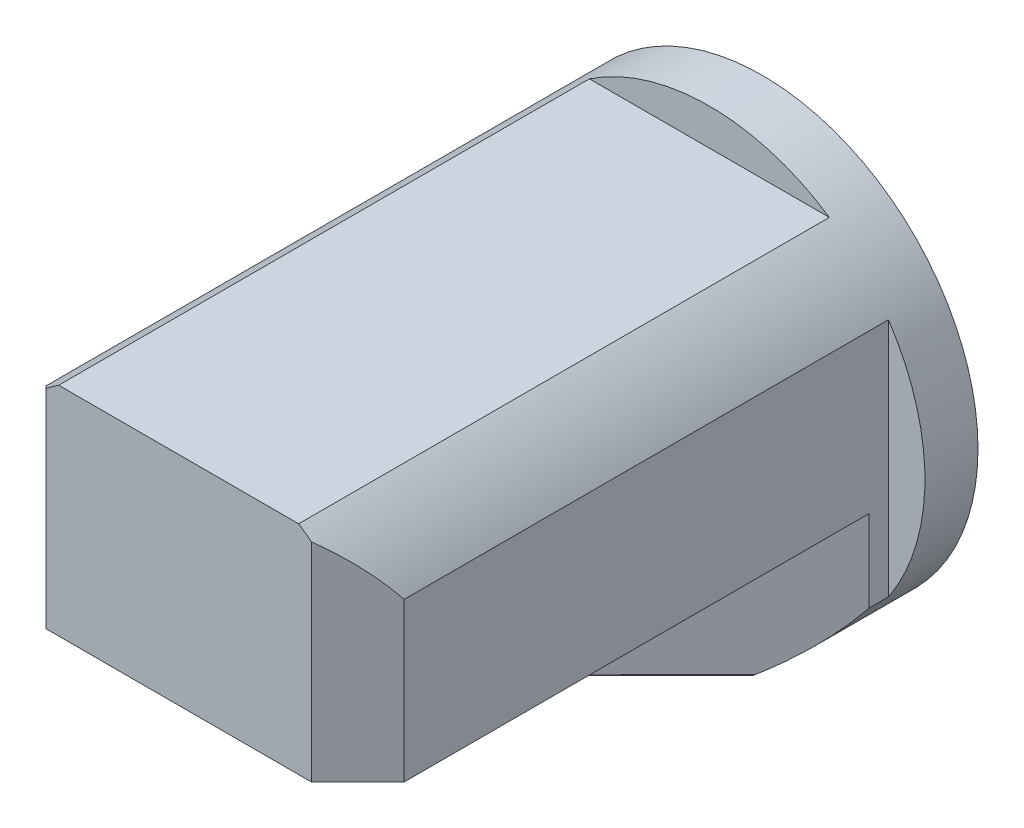
from build123d import *

# Parameters (mm, degrees)
SKETCH3_R             = 130
BOSS_EXTRUDE1_DEPTH   = 352
CUT_EXTRUDE2_START    = -320
CUT_EXTRUDE2_DEPTH    = 320
CUT_EXTRUDE3_START    = -320
CUT_EXTRUDE3_DEPTH    = 320
CUT_EXTRUDE4_DEPTH    = 85
CUT_EXTRUDE5_DEPTH    = 85
CUT_EXTRUDE7_REACH    = 420.413
CUT_EXTRUDE8_REACH    = 420.413
CUT_EXTRUDE9_DEPTH    = 285
SKETCH22_W            = 60
SKETCH22_H            = 60
BOSS_EXTRUDE3_DEPTH   = 2
FILLET1_R             = 3
FILLET2_R             = 3
FILLET4_R             = 1
FILLET5_R             = 1
BODY_MOVE_COPY2_ANGLE = 90
BODY_MOVE_COPY3_ANGLE = 90
BODY_MOVE_COPY4_ANGLE = 180


with BuildPart() as part:
    # Sketch3 → Boss-Extrude1 (new body)
    with BuildSketch(Plane(origin=(0, 0, 0), x_dir=(1, 0, 0), z_dir=(0, 1, 0))):
        Circle(SKETCH3_R)
    extrude(amount=BOSS_EXTRUDE1_DEPTH)

    # Sketch11 → Cut-Extrude2 (cut)
    with BuildSketch(Plane(origin=(0, 352, 0), x_dir=(1, 0, 0), z_dir=(0, 1, 0)).offset(CUT_EXTRUDE2_START)):
        with BuildLine():
            Line((72.360210061, -108), (-72.360210061, -108))
            ThreePointArc((-72.360210061, -108), (0, -130), (72.360210061, -108))
        make_face()
        with BuildLine():
            Line((-72.360210061, 108), (72.360210061, 108))
            ThreePointArc((72.360210061, 108), (0, 130), (-72.360210061, 108))
        make_face()
    extrude(amount=CUT_EXTRUDE2_DEPTH, mode=Mode.SUBTRACT)

    # Sketch11_4 → Cut-Extrude3 (cut)
    with BuildSketch(Plane(origin=(0, 352, 0), x_dir=(1, 0, 0), z_dir=(0, 1, 0)).offset(CUT_EXTRUDE3_START)):
        with BuildLine():
            Line((108, 72.360210061), (108, -72.360210061))
            ThreePointArc((108, -72.360210061), (130, 0), (108, 72.360210061))
        make_face()
        with BuildLine():
            ThreePointArc((-108, 72.360210061), (-130, 0), (-108, -72.360210061))
            Line((-108, -72.360210061), (-108, 72.360210061))
        make_face()
    extrude(amount=CUT_EXTRUDE3_DEPTH, mode=Mode.SUBTRACT)

    # Sketch12 → Cut-Extrude4 (cut)
    with BuildSketch(Plane.ZY.offset(108)):
        Polygon((-72.360210061, 137), (0, 137), (72.360210061, 137), (72.360210061, 352), (-72.360210061, 352), align=None)
    extrude(amount=-CUT_EXTRUDE4_DEPTH, mode=Mode.SUBTRACT)

    # Sketch14 → Cut-Extrude5 (cut)
    with BuildSketch(Plane.ZY.offset(108)):
        Polygon((-72.360210061, 79.254886678), (-14.615096739, 137), (-72.360210061, 137), align=None)
        Polygon((72.360210061, 137), (14.615096739, 137), (72.360210061, 79.254886678), align=None)
    extrude(amount=-CUT_EXTRUDE5_DEPTH, mode=Mode.SUBTRACT)

    # Cut-Extrude7: up to this plane
    cut_extrude7_end = Plane(origin=(-23, 75.807548369, -75.807548369), z_dir=(0, 0.7071067811865563, -0.7071067811865388))
    # Sketch15 → Cut-Extrude7 (cut, up to the surface)
    with BuildSketch(Plane(origin=(0, 352, 0), x_dir=(1, 0, 0), z_dir=(0, 1, 0)), mode=Mode.PRIVATE) as cut_extrude7_sk1:
        with BuildLine():
            Line((-108, 72.360210061), (-23, 72.360210061))
            Line((-23, 72.360210061), (-23, 108))
            Line((-23, 108), (-72.360210061, 108))
            ThreePointArc((-72.360210061, 108), (-91.923881554, 91.923881554), (-108, 72.360210061))
        make_face()
    cut_extrude7_tool1 = split(extrude(cut_extrude7_sk1.sketch, amount=-CUT_EXTRUDE7_REACH, mode=Mode.PRIVATE), bisect_by=cut_extrude7_end, keep=Keep.BOTH, mode=Mode.PRIVATE)
    add(cut_extrude7_tool1.solids().sort_by_distance((-58.500557, 352, -88.680695))[0], mode=Mode.SUBTRACT)

    # Cut-Extrude8: up to this plane
    cut_extrude8_end = Plane(origin=(-23, 75.807548369, 75.807548369), z_dir=(0, -0.7071067811865561, -0.707106781186539))
    # Sketch15_4 → Cut-Extrude8 (cut, up to the surface)
    with BuildSketch(Plane(origin=(0, 352, 0), x_dir=(1, 0, 0), z_dir=(0, 1, 0)), mode=Mode.PRIVATE) as cut_extrude8_sk1:
        with BuildLine():
            Line((-23, -108), (-23, -72.360210061))
            Line((-23, -72.360210061), (-108, -72.360210061))
            ThreePointArc((-108, -72.360210061), (-91.923881554, -91.923881554), (-72.360210061, -108))
            Line((-72.360210061, -108), (-23, -108))
        make_face()
    cut_extrude8_tool1 = split(extrude(cut_extrude8_sk1.sketch, amount=-CUT_EXTRUDE8_REACH, mode=Mode.PRIVATE), bisect_by=cut_extrude8_end, keep=Keep.BOTH, mode=Mode.PRIVATE)
    add(cut_extrude8_tool1.solids().sort_by_distance((-58.500557, 352, 88.680695))[0], mode=Mode.SUBTRACT)

    # Sketch18 → Cut-Extrude9 (cut)
    with BuildSketch(Plane.ZY.offset(23)):
        Polygon((-108, 324), (-80, 352), (-108, 352), align=None)
        Polygon((108, 352), (80, 352), (108, 324), align=None)
    extrude(amount=-CUT_EXTRUDE9_DEPTH, mode=Mode.SUBTRACT)

    # Sketch22 → Boss-Extrude3 (add)
    with BuildSketch(Plane.ZY.offset(108)):
        with Locations((-13.4876534, 78.127443339)):
            Rectangle(SKETCH22_W, SKETCH22_H)
    extrude(amount=BOSS_EXTRUDE3_DEPTH)

    # Fillet1
    fillet1_edges = [part.edges().sort_by_distance(p)[0] for p in [
        (-109, 108.127443339, -43.4876534),
    ]]
    fillet(fillet1_edges, radius=FILLET1_R)

    # Fillet2
    fillet2_edges = [part.edges().sort_by_distance(p)[0] for p in [
        (-109, 48.127443339, -43.4876534),
        (-109, 48.127443339, 16.5123466),
        (-109, 108.127443339, 16.5123466),
    ]]
    fillet(fillet2_edges, radius=FILLET2_R)

    # Fillet4
    fillet4_edges = [part.edges().sort_by_distance(p)[0] for p in [
        (-108, 108.127443339, -43.4876534),
        (-108, 108.127443339, -43.4876534),
        (-108, 108.127443339, 43.4876534),
    ]]
    fillet(fillet4_edges, radius=FILLET4_R)

    # Fillet5
    fillet5_edges = [part.edges().sort_by_distance(p)[0] for p in [
        (-108, 107.248763683, -42.608973743),
        (-108, 78.127443339, -43.4876534),
        (-108, 49.006122995, -42.608973743),
        (-108, 48.127443339, -13.4876534),
        (-108, 49.006122995, 15.633666944),
        (-108, 78.127443339, 16.5123466),
        (-108, 107.248763683, 15.633666944),
        (-108, 108.127443339, -13.4876534),
    ]]
    fillet(fillet5_edges, radius=FILLET5_R)


with BuildPart() as part_1:
    # Body-Move_Copy2: moved
    add(part.part.rotate(Axis((0, 0, 0), (1, 0, 0)), BODY_MOVE_COPY2_ANGLE))


with BuildPart() as part_2:
    # Body-Move_Copy3: moved
    add(part_1.part.rotate(Axis((0, 0, 0), (0, 0, -1)), BODY_MOVE_COPY3_ANGLE))


with BuildPart() as part_3:
    # Body-Move_Copy4: moved
    add(part_2.part.rotate(Axis((0, 0, 0), (0, 0, 1)), BODY_MOVE_COPY4_ANGLE))


solid = part_3.part
